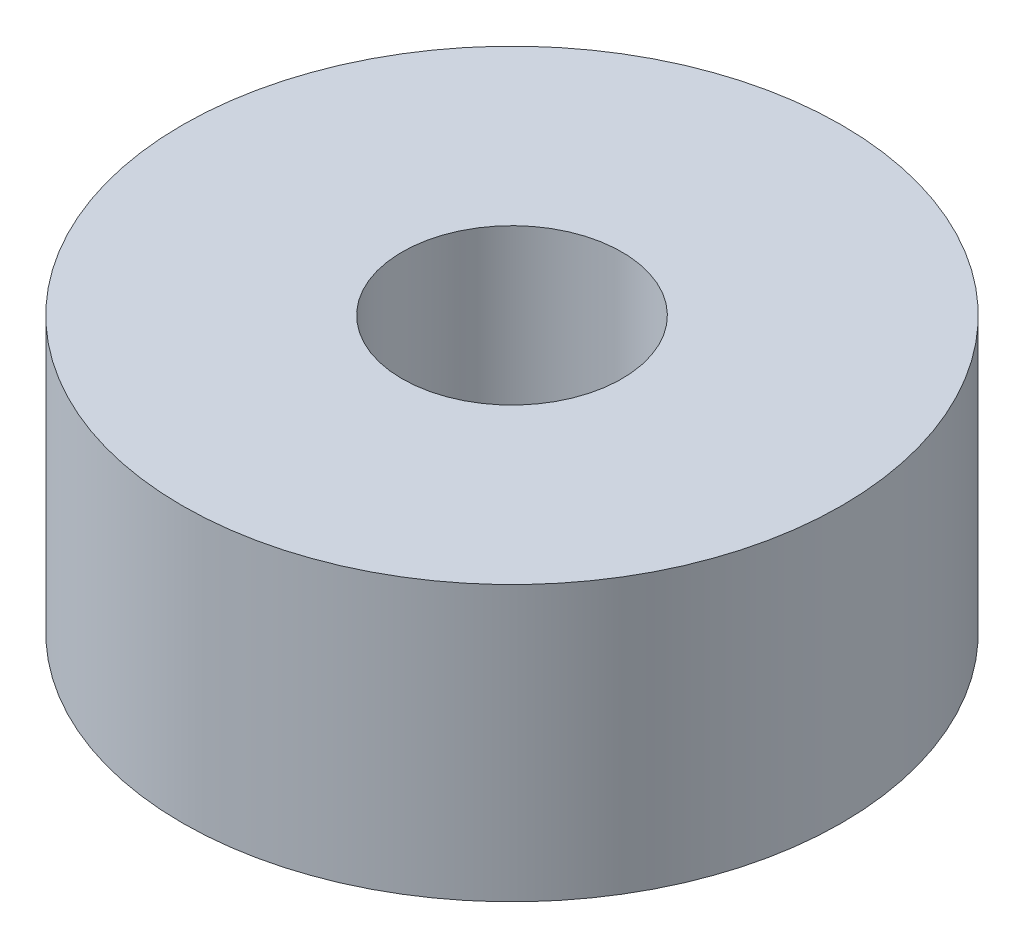
from build123d import *

# Parameters (mm, degrees)
SKETCH_1_R      = 3
SKETCH_1_R_2    = 1
EXTRUDE_1_DEPTH = 2.5


with BuildPart() as part:
    # 草图1 → 凸台-拉伸1 (new body)
    with BuildSketch(Plane(origin=(0, 0, 0), x_dir=(1, 0, 0), z_dir=(0, 1, 0))):
        Circle(SKETCH_1_R)
        Circle(SKETCH_1_R_2, mode=Mode.SUBTRACT)
    extrude(amount=EXTRUDE_1_DEPTH)


solid = part.part
